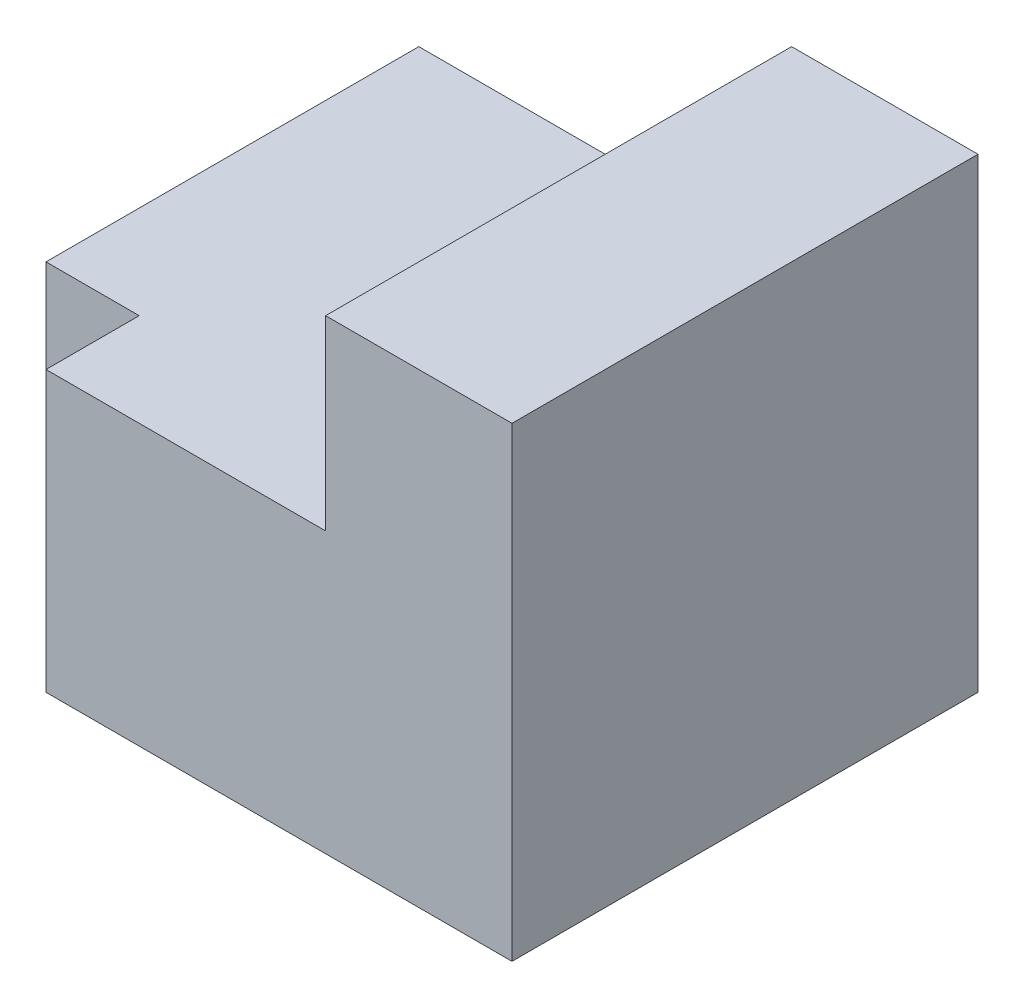
from build123d import *

# Parameters (mm, degrees)
SKETCH1_W           = 60
SKETCH1_H           = 30
BOSS_EXTRUDE1_DEPTH = 50
BOSS_EXTRUDE2_DEPTH = 50
SKETCH3_W           = 10
SKETCH3_H           = 30
CUT_EXTRUDE1_DEPTH  = 10
CUT_EXTRUDE2_DEPTH  = 30
CUT_EXTRUDE3_DEPTH  = 10
BOSS_EXTRUDE3_DEPTH = 10


with BuildPart() as part:
    # Sketch1 → Boss-Extrude1 (new body)
    with BuildSketch(Plane.XY):
        with Locations((30, 15)):
            Rectangle(SKETCH1_W, SKETCH1_H)
    extrude(amount=BOSS_EXTRUDE1_DEPTH)

    # Sketch2 → Boss-Extrude2 (add)
    with BuildSketch(Plane.XY.offset(50)):
        Polygon((60, 30), (60, 50), (40, 50), (20, 30), align=None)
    extrude(amount=-BOSS_EXTRUDE2_DEPTH)

    # Sketch3 → Cut-Extrude1 (cut)
    with BuildSketch(Plane.XY.offset(50)):
        with Locations((5, 15)):
            Rectangle(SKETCH3_W, SKETCH3_H)
    extrude(amount=-CUT_EXTRUDE1_DEPTH, mode=Mode.SUBTRACT)

    # Sketch4 → Cut-Extrude2 (cut)
    with BuildSketch(Plane.XY.offset(50)):
        Polygon((40, 50), (20, 30), (40, 30), align=None)
    extrude(amount=-CUT_EXTRUDE2_DEPTH, mode=Mode.SUBTRACT)

    # Sketch5 → Cut-Extrude3 (cut)
    with BuildSketch(Plane(origin=(0, 0, 0), x_dir=(-1, 0, 0), z_dir=(0, 0, -1))):
        Polygon((-20, 30), (-40, 50), (-40, 30), align=None)
    extrude(amount=-CUT_EXTRUDE3_DEPTH, mode=Mode.SUBTRACT)

    # Sketch6 → Boss-Extrude3 (add)
    with BuildSketch(Plane.XY.offset(20)):
        Polygon((20, 30), (40, 30), (40, 50), align=None)
    extrude(amount=BOSS_EXTRUDE3_DEPTH)


solid = part.part
